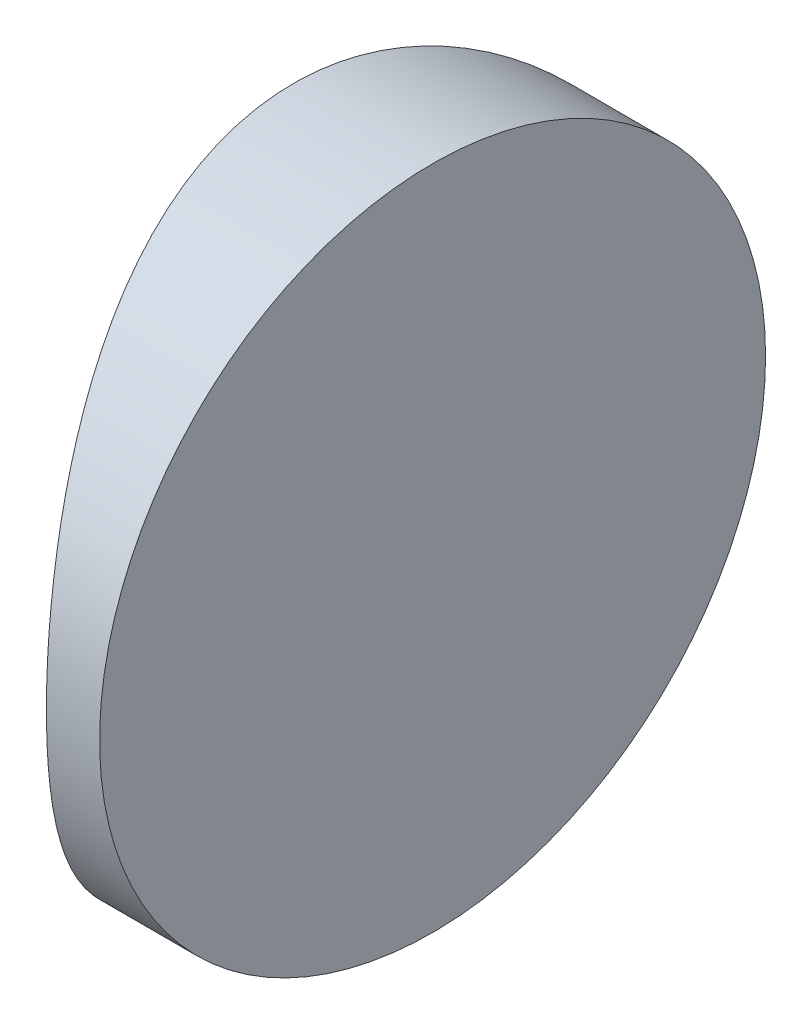
from build123d import *

# Parameters (mm, degrees)
EXTRUDE_1_DEPTH     = 25
CUT_EXTRUDE_8_DEPTH = 12.7


with BuildPart() as part:
    # 草图1 → 凸台-拉伸1 (new body)
    with BuildSketch(Plane(origin=(0, 0, 0), x_dir=(1, 0, 0), z_dir=(0, 1, 0))):
        with BuildLine():
            Line((-18.271604985, 12.5), (-16.274795665, 12.5))
            Line((-16.274795665, 12.5), (-16.274795665, -12.5))
            Line((-16.274795665, -12.5), (-18.271604985, -12.5))
            ThreePointArc((-18.271604985, -12.5), (-21.494795665, 0), (-18.271604985, 12.5))
        make_face()
    extrude(amount=EXTRUDE_1_DEPTH)

    # 草图2 → 切除-拉伸8 (cut)
    with BuildSketch(Plane(origin=(-16.274795665, 0, 0), x_dir=(0, 0, -1), z_dir=(1, 0, 0))):
        with BuildLine():
            Line((-12.5, 25), (-12.5, 12.5))
            ThreePointArc((-12.5, 12.5), (-8.838834765, 21.338834765), (0, 25))
            Line((0, 25), (-12.5, 25))
        make_face()
        with BuildLine():
            ThreePointArc((0, 25), (8.838834765, 21.338834765), (12.5, 12.5))
            Line((12.5, 12.5), (12.5, 25))
            Line((12.5, 25), (0, 25))
        make_face()
        with BuildLine():
            ThreePointArc((12.5, 12.5), (8.838834765, 3.661165235), (0, 0))
            Line((0, 0), (12.5, 0))
            Line((12.5, 0), (12.5, 12.5))
        make_face()
        with BuildLine():
            Line((-12.5, 12.5), (-12.5, 0))
            Line((-12.5, 0), (0, 0))
            ThreePointArc((0, 0), (-8.838834765, 3.661165235), (-12.5, 12.5))
        make_face()
    extrude(amount=-CUT_EXTRUDE_8_DEPTH, mode=Mode.SUBTRACT)


solid = part.part
